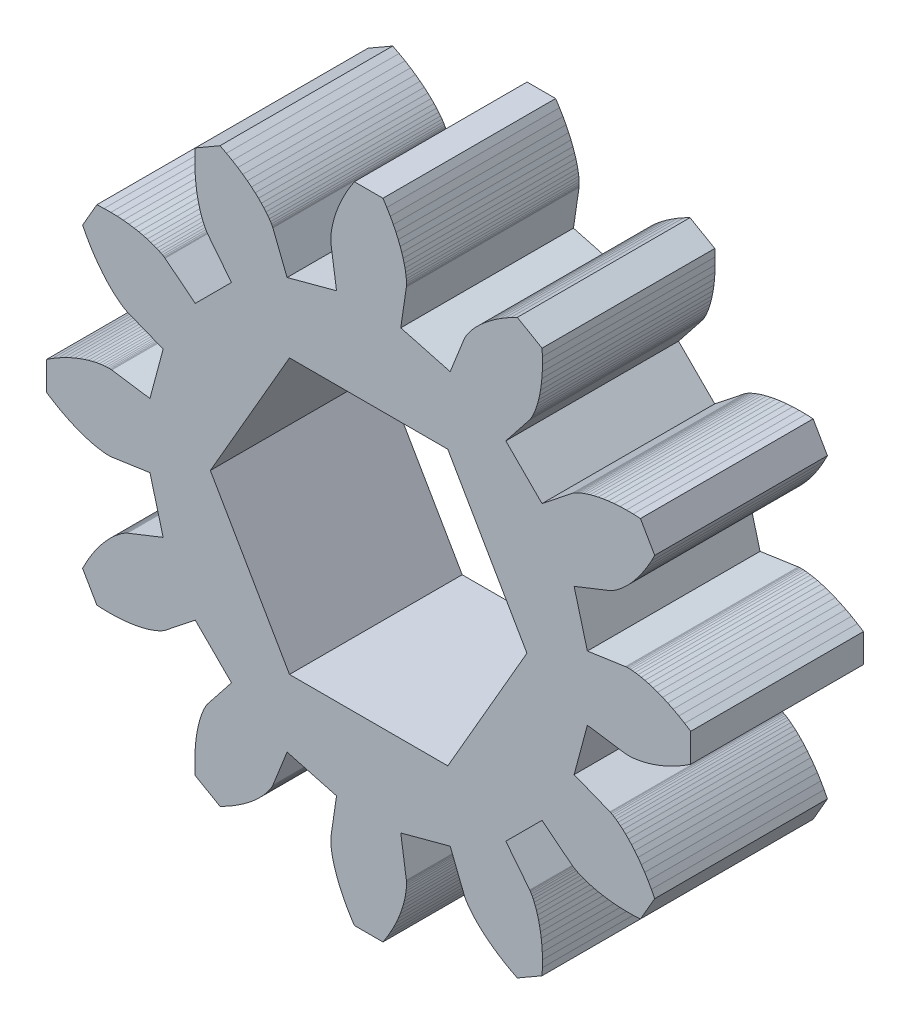
from build123d import *

# Parameters (mm, degrees)
BOSS_EXTRUDE1_DEPTH = 3


with BuildPart() as part:
    # Model → Boss-Extrude1 (new, symmetric)
    with BuildSketch(Plane.XY):
        Polygon((7.598510658, 1.115811715), (8.925330493, 1.310650044), (8.932046436, 1.311459751), (8.952265558, 1.313193968), (8.98604931, 1.314806512), (9.033398327, 1.315248614), (9.094252351, 1.313472056), (9.168490306, 1.308432321), (9.255930522, 1.29909172), (9.356331115, 1.284422524), (9.469390516, 1.263410063), (9.594748147, 1.235055805), (9.731985251, 1.198380394), (9.880625865, 1.152426655), (10.040137939, 1.096262546), (10.209934597, 1.028984054), (10.38937554, 0.94971804), (10.577768582, 0.857624999), (10.774371324, 0.751901763), (10.978392958, 0.631784118), (11.188996194, 0.496549327), (11.188996194, -0.496549327), (10.978392958, -0.631784118), (10.774371324, -0.751901763), (10.577768582, -0.857624999), (10.38937554, -0.94971804), (10.209934597, -1.028984054), (10.040137939, -1.096262546), (9.880625865, -1.152426655), (9.731985251, -1.198380394), (9.594748147, -1.235055805), (9.469390516, -1.263410063), (9.356331115, -1.284422524), (9.255930522, -1.29909172), (9.168490306, -1.308432321), (9.094252351, -1.313472056), (9.033398327, -1.315248614), (8.98604931, -1.314806512), (8.952265558, -1.313193968), (8.932046436, -1.311459751), (8.925330493, -1.310650044), (7.598510658, -1.115811715), (7.138409118, -2.832934038), (8.384887966, -3.327609013), (8.391108997, -3.330265757), (8.409486378, -3.338873443), (8.439550238, -3.354368814), (8.48077674, -3.377660452), (8.532589592, -3.409626008), (8.594361679, -3.451109524), (8.665416827, -3.50291883), (8.745031694, -3.565823023), (8.832437777, -3.640550048), (8.926823541, -3.727784371), (9.027336653, -3.828164761), (9.133086332, -3.942282173), (9.243145786, -4.070677756), (9.35655476, -4.213840968), (9.472322167, -4.372207821), (9.589428807, -4.546159255), (9.706830158, -4.736019634), (9.823459253, -4.942055383), (9.93822961, -5.164473766), (9.441680283, -6.024522428), (9.191675135, -6.036337575), (8.954928395, -6.03835169), (8.731803808, -6.031609327), (8.522604127, -6.017167719), (8.327570705, -5.99609363), (8.14688324, -5.969460183), (7.980659677, -5.938343692), (7.82895626, -5.90382049), (7.691767736, -5.866963776), (7.569027714, -5.828840468), (7.46060917, -5.790508092), (7.366325108, -5.753011692), (7.285929359, -5.717380782), (7.219117536, -5.684626343), (7.165528127, -5.655737875), (7.124743726, -5.631680495), (7.096292411, -5.613392115), (7.079649245, -5.601780678), (7.074237922, -5.59772148), (6.022597403, -4.76557662), (4.76557662, -6.022597403), (5.59772148, -7.074237922), (5.601780678, -7.079649245), (5.613392115, -7.096292411), (5.631680495, -7.124743726), (5.655737875, -7.165528127), (5.684626343, -7.219117536), (5.717380782, -7.285929359), (5.753011692, -7.366325108), (5.790508092, -7.46060917), (5.828840468, -7.569027714), (5.866963776, -7.691767736), (5.90382049, -7.82895626), (5.938343692, -7.980659677), (5.969460183, -8.14688324), (5.99609363, -8.327570705), (6.017167719, -8.522604127), (6.031609327, -8.731803808), (6.03835169, -8.954928395), (6.036337575, -9.191675135), (6.024522428, -9.441680283), (5.164473766, -9.93822961), (4.942055383, -9.823459253), (4.736019634, -9.706830158), (4.546159255, -9.589428807), (4.372207821, -9.472322167), (4.213840968, -9.35655476), (4.070677756, -9.243145786), (3.942282173, -9.133086332), (3.828164761, -9.027336653), (3.727784371, -8.926823541), (3.640550048, -8.832437777), (3.565823023, -8.745031694), (3.50291883, -8.665416827), (3.451109524, -8.594361679), (3.409626008, -8.532589592), (3.377660452, -8.48077674), (3.354368814, -8.439550238), (3.338873443, -8.409486378), (3.330265757, -8.391108997), (3.327609013, -8.384887966), (2.832934038, -7.138409118), (1.115811715, -7.598510658), (1.310650044, -8.925330493), (1.311459751, -8.932046436), (1.313193968, -8.952265558), (1.314806512, -8.98604931), (1.315248614, -9.033398327), (1.313472056, -9.094252351), (1.308432321, -9.168490306), (1.29909172, -9.255930522), (1.284422524, -9.356331115), (1.263410063, -9.469390516), (1.235055805, -9.594748147), (1.198380394, -9.731985251), (1.152426655, -9.880625865), (1.096262546, -10.040137939), (1.028984054, -10.209934597), (0.94971804, -10.38937554), (0.857624999, -10.577768582), (0.751901763, -10.774371324), (0.631784118, -10.978392958), (0.496549327, -11.188996194), (-0.496549327, -11.188996194), (-0.631784118, -10.978392958), (-0.751901763, -10.774371324), (-0.857624999, -10.577768582), (-0.94971804, -10.38937554), (-1.028984054, -10.209934597), (-1.096262546, -10.040137939), (-1.152426655, -9.880625865), (-1.198380394, -9.731985251), (-1.235055805, -9.594748147), (-1.263410063, -9.469390516), (-1.284422524, -9.356331115), (-1.29909172, -9.255930522), (-1.308432321, -9.168490306), (-1.313472056, -9.094252351), (-1.315248614, -9.033398327), (-1.314806512, -8.98604931), (-1.313193968, -8.952265558), (-1.311459751, -8.932046436), (-1.310650044, -8.925330493), (-1.115811715, -7.598510658), (-2.832934038, -7.138409118), (-3.327609013, -8.384887966), (-3.330265757, -8.391108997), (-3.338873443, -8.409486378), (-3.354368814, -8.439550238), (-3.377660452, -8.48077674), (-3.409626008, -8.532589592), (-3.451109524, -8.594361679), (-3.50291883, -8.665416827), (-3.565823023, -8.745031694), (-3.640550048, -8.832437777), (-3.727784371, -8.926823541), (-3.828164761, -9.027336653), (-3.942282173, -9.133086332), (-4.070677756, -9.243145786), (-4.213840968, -9.35655476), (-4.372207821, -9.472322167), (-4.546159255, -9.589428807), (-4.736019634, -9.706830158), (-4.942055383, -9.823459253), (-5.164473766, -9.93822961), (-6.024522428, -9.441680283), (-6.036337575, -9.191675135), (-6.03835169, -8.954928395), (-6.031609327, -8.731803808), (-6.017167719, -8.522604127), (-5.99609363, -8.327570705), (-5.969460183, -8.14688324), (-5.938343692, -7.980659677), (-5.90382049, -7.82895626), (-5.866963776, -7.691767736), (-5.828840468, -7.569027714), (-5.790508092, -7.46060917), (-5.753011692, -7.366325108), (-5.717380782, -7.285929359), (-5.684626343, -7.219117536), (-5.655737875, -7.165528127), (-5.631680495, -7.124743726), (-5.613392115, -7.096292411), (-5.601780678, -7.079649245), (-5.59772148, -7.074237922), (-4.76557662, -6.022597403), (-6.022597403, -4.76557662), (-7.074237922, -5.59772148), (-7.079649245, -5.601780678), (-7.096292411, -5.613392115), (-7.124743726, -5.631680495), (-7.165528127, -5.655737875), (-7.219117536, -5.684626343), (-7.285929359, -5.717380782), (-7.366325108, -5.753011692), (-7.46060917, -5.790508092), (-7.569027714, -5.828840468), (-7.691767736, -5.866963776), (-7.82895626, -5.90382049), (-7.980659677, -5.938343692), (-8.14688324, -5.969460183), (-8.327570705, -5.99609363), (-8.522604127, -6.017167719), (-8.731803808, -6.031609327), (-8.954928395, -6.03835169), (-9.191675135, -6.036337575), (-9.441680283, -6.024522428), (-9.93822961, -5.164473766), (-9.823459253, -4.942055383), (-9.706830158, -4.736019634), (-9.589428807, -4.546159255), (-9.472322167, -4.372207821), (-9.35655476, -4.213840968), (-9.243145786, -4.070677756), (-9.133086332, -3.942282173), (-9.027336653, -3.828164761), (-8.926823541, -3.727784371), (-8.832437777, -3.640550048), (-8.745031694, -3.565823023), (-8.665416827, -3.50291883), (-8.594361679, -3.451109524), (-8.532589592, -3.409626008), (-8.48077674, -3.377660452), (-8.439550238, -3.354368814), (-8.409486378, -3.338873443), (-8.391108997, -3.330265757), (-8.384887966, -3.327609013), (-7.138409118, -2.832934038), (-7.598510658, -1.115811715), (-8.925330493, -1.310650044), (-8.932046436, -1.311459751), (-8.952265558, -1.313193968), (-8.98604931, -1.314806512), (-9.033398327, -1.315248614), (-9.094252351, -1.313472056), (-9.168490306, -1.308432321), (-9.255930522, -1.29909172), (-9.356331115, -1.284422524), (-9.469390516, -1.263410063), (-9.594748147, -1.235055805), (-9.731985251, -1.198380394), (-9.880625865, -1.152426655), (-10.040137939, -1.096262546), (-10.209934597, -1.028984054), (-10.38937554, -0.94971804), (-10.577768582, -0.857624999), (-10.774371324, -0.751901763), (-10.978392958, -0.631784118), (-11.188996194, -0.496549327), (-11.188996194, 0.496549327), (-10.978392958, 0.631784118), (-10.774371324, 0.751901763), (-10.577768582, 0.857624999), (-10.38937554, 0.94971804), (-10.209934597, 1.028984054), (-10.040137939, 1.096262546), (-9.880625865, 1.152426655), (-9.731985251, 1.198380394), (-9.594748147, 1.235055805), (-9.469390516, 1.263410063), (-9.356331115, 1.284422524), (-9.255930522, 1.29909172), (-9.168490306, 1.308432321), (-9.094252351, 1.313472056), (-9.033398327, 1.315248614), (-8.98604931, 1.314806512), (-8.952265558, 1.313193968), (-8.932046436, 1.311459751), (-8.925330493, 1.310650044), (-7.598510658, 1.115811715), (-7.138409118, 2.832934038), (-8.384887966, 3.327609013), (-8.391108997, 3.330265757), (-8.409486378, 3.338873443), (-8.439550238, 3.354368814), (-8.48077674, 3.377660452), (-8.532589592, 3.409626008), (-8.594361679, 3.451109524), (-8.665416827, 3.50291883), (-8.745031694, 3.565823023), (-8.832437777, 3.640550048), (-8.926823541, 3.727784371), (-9.027336653, 3.828164761), (-9.133086332, 3.942282173), (-9.243145786, 4.070677756), (-9.35655476, 4.213840968), (-9.472322167, 4.372207821), (-9.589428807, 4.546159255), (-9.706830158, 4.736019634), (-9.823459253, 4.942055383), (-9.93822961, 5.164473766), (-9.441680283, 6.024522428), (-9.191675135, 6.036337575), (-8.954928395, 6.03835169), (-8.731803808, 6.031609327), (-8.522604127, 6.017167719), (-8.327570705, 5.99609363), (-8.14688324, 5.969460183), (-7.980659677, 5.938343692), (-7.82895626, 5.90382049), (-7.691767736, 5.866963776), (-7.569027714, 5.828840468), (-7.46060917, 5.790508092), (-7.366325108, 5.753011692), (-7.285929359, 5.717380782), (-7.219117536, 5.684626343), (-7.165528127, 5.655737875), (-7.124743726, 5.631680495), (-7.096292411, 5.613392115), (-7.079649245, 5.601780678), (-7.074237922, 5.59772148), (-6.022597403, 4.76557662), (-4.76557662, 6.022597403), (-5.59772148, 7.074237922), (-5.601780678, 7.079649245), (-5.613392115, 7.096292411), (-5.631680495, 7.124743726), (-5.655737875, 7.165528127), (-5.684626343, 7.219117536), (-5.717380782, 7.285929359), (-5.753011692, 7.366325108), (-5.790508092, 7.46060917), (-5.828840468, 7.569027714), (-5.866963776, 7.691767736), (-5.90382049, 7.82895626), (-5.938343692, 7.980659677), (-5.969460183, 8.14688324), (-5.99609363, 8.327570705), (-6.017167719, 8.522604127), (-6.031609327, 8.731803808), (-6.03835169, 8.954928395), (-6.036337575, 9.191675135), (-6.024522428, 9.441680283), (-5.164473766, 9.93822961), (-4.942055383, 9.823459253), (-4.736019634, 9.706830158), (-4.546159255, 9.589428807), (-4.372207821, 9.472322167), (-4.213840968, 9.35655476), (-4.070677756, 9.243145786), (-3.942282173, 9.133086332), (-3.828164761, 9.027336653), (-3.727784371, 8.926823541), (-3.640550048, 8.832437777), (-3.565823023, 8.745031694), (-3.50291883, 8.665416827), (-3.451109524, 8.594361679), (-3.409626008, 8.532589592), (-3.377660452, 8.48077674), (-3.354368814, 8.439550238), (-3.338873443, 8.409486378), (-3.330265757, 8.391108997), (-3.327609013, 8.384887966), (-2.832934038, 7.138409118), (-1.115811715, 7.598510658), (-1.310650044, 8.925330493), (-1.311459751, 8.932046436), (-1.313193968, 8.952265558), (-1.314806512, 8.98604931), (-1.315248614, 9.033398327), (-1.313472056, 9.094252351), (-1.308432321, 9.168490306), (-1.29909172, 9.255930522), (-1.284422524, 9.356331115), (-1.263410063, 9.469390516), (-1.235055805, 9.594748147), (-1.198380394, 9.731985251), (-1.152426655, 9.880625865), (-1.096262546, 10.040137939), (-1.028984054, 10.209934597), (-0.94971804, 10.38937554), (-0.857624999, 10.577768582), (-0.751901763, 10.774371324), (-0.631784118, 10.978392958), (-0.496549327, 11.188996194), (0.496549327, 11.188996194), (0.631784118, 10.978392958), (0.751901763, 10.774371324), (0.857624999, 10.577768582), (0.94971804, 10.38937554), (1.028984054, 10.209934597), (1.096262546, 10.040137939), (1.152426655, 9.880625865), (1.198380394, 9.731985251), (1.235055805, 9.594748147), (1.263410063, 9.469390516), (1.284422524, 9.356331115), (1.29909172, 9.255930522), (1.308432321, 9.168490306), (1.313472056, 9.094252351), (1.315248614, 9.033398327), (1.314806512, 8.98604931), (1.313193968, 8.952265558), (1.311459751, 8.932046436), (1.310650044, 8.925330493), (1.115811715, 7.598510658), (2.832934038, 7.138409118), (3.327609013, 8.384887966), (3.330265757, 8.391108997), (3.338873443, 8.409486378), (3.354368814, 8.439550238), (3.377660452, 8.48077674), (3.409626008, 8.532589592), (3.451109524, 8.594361679), (3.50291883, 8.665416827), (3.565823023, 8.745031694), (3.640550048, 8.832437777), (3.727784371, 8.926823541), (3.828164761, 9.027336653), (3.942282173, 9.133086332), (4.070677756, 9.243145786), (4.213840968, 9.35655476), (4.372207821, 9.472322167), (4.546159255, 9.589428807), (4.736019634, 9.706830158), (4.942055383, 9.823459253), (5.164473766, 9.93822961), (6.024522428, 9.441680283), (6.036337575, 9.191675135), (6.03835169, 8.954928395), (6.031609327, 8.731803808), (6.017167719, 8.522604127), (5.99609363, 8.327570705), (5.969460183, 8.14688324), (5.938343692, 7.980659677), (5.90382049, 7.82895626), (5.866963776, 7.691767736), (5.828840468, 7.569027714), (5.790508092, 7.46060917), (5.753011692, 7.366325108), (5.717380782, 7.285929359), (5.684626343, 7.219117536), (5.655737875, 7.165528127), (5.631680495, 7.124743726), (5.613392115, 7.096292411), (5.601780678, 7.079649245), (5.59772148, 7.074237922), (4.76557662, 6.022597403), (6.022597403, 4.76557662), (7.074237922, 5.59772148), (7.079649245, 5.601780678), (7.096292411, 5.613392115), (7.124743726, 5.631680495), (7.165528127, 5.655737875), (7.219117536, 5.684626343), (7.285929359, 5.717380782), (7.366325108, 5.753011692), (7.46060917, 5.790508092), (7.569027714, 5.828840468), (7.691767736, 5.866963776), (7.82895626, 5.90382049), (7.980659677, 5.938343692), (8.14688324, 5.969460183), (8.327570705, 5.99609363), (8.522604127, 6.017167719), (8.731803808, 6.031609327), (8.954928395, 6.03835169), (9.191675135, 6.036337575), (9.441680283, 6.024522428), (9.93822961, 5.164473766), (9.823459253, 4.942055383), (9.706830158, 4.736019634), (9.589428807, 4.546159255), (9.472322167, 4.372207821), (9.35655476, 4.213840968), (9.243145786, 4.070677756), (9.133086332, 3.942282173), (9.027336653, 3.828164761), (8.926823541, 3.727784371), (8.832437777, 3.640550048), (8.745031694, 3.565823023), (8.665416827, 3.50291883), (8.594361679, 3.451109524), (8.532589592, 3.409626008), (8.48077674, 3.377660452), (8.439550238, 3.354368814), (8.409486378, 3.338873443), (8.391108997, 3.330265757), (8.384887966, 3.327609013), (7.138409118, 2.832934038), align=None)
        Polygon((5.499261314, 0), (2.749630657, 4.7625), (-2.749630657, 4.7625), (-5.499261314, 0), (-2.749630657, -4.7625), (2.749630657, -4.7625), align=None, mode=Mode.SUBTRACT)
    extrude(amount=BOSS_EXTRUDE1_DEPTH, both=True)


solid = part.part
